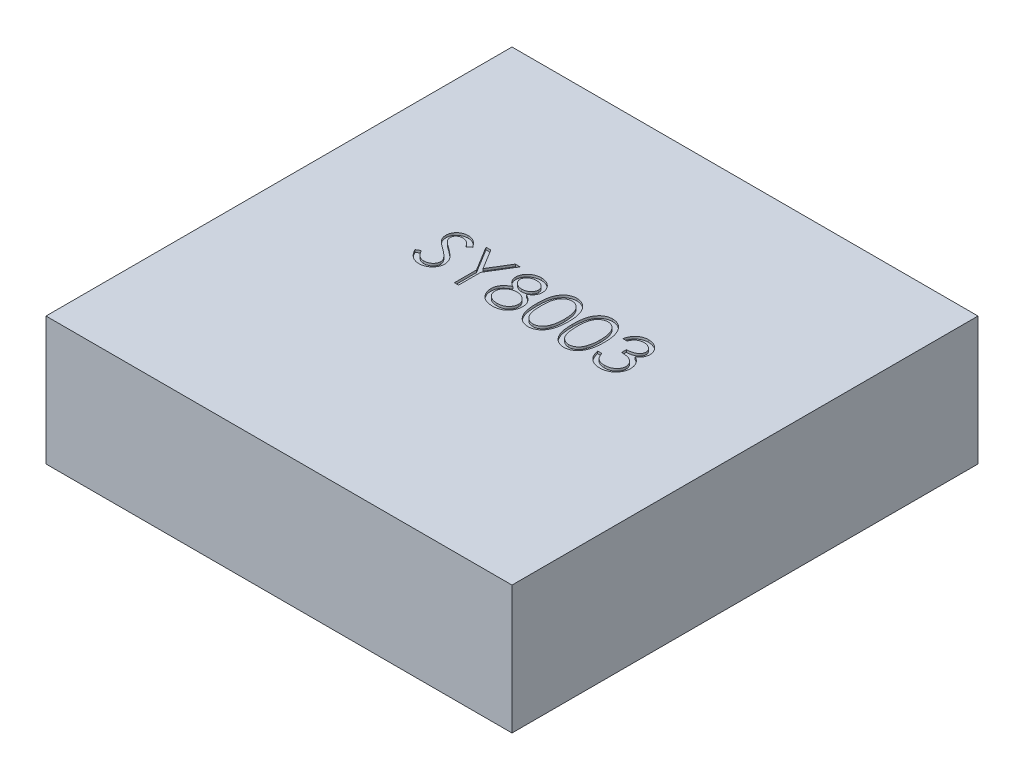
from build123d import *

# Parameters (mm, degrees)
BASES_W          = 2
BASES_H          = 2
BASE_DEPTH       = 0.55
PARTNUMBER_DEPTH = 0.01


with BuildPart() as part:
    # BaseS → Base (new body)
    with BuildSketch(Plane(origin=(0, 0, 0), x_dir=(1, 0, 0), z_dir=(0, 1, 0))):
        Rectangle(BASES_W, BASES_H)
    extrude(amount=BASE_DEPTH)

    # PartNumberS → PartNumber (cut)
    with BuildSketch(Plane(origin=(0, 0.55, 0), x_dir=(1, 0, 0), z_dir=(0, 1, 0))):
        with BuildLine():
            Line((0.33974359, 0.153846154), (0.321794872, 0.153846154))
            add(Edge.make_bspline(
                [(0.321794872, 0.153846154), (0.322281132, 0.155859439), (0.32323173, 0.159795246), (0.325214449, 0.165418518), (0.327374406, 0.170739862), (0.329968069, 0.175659638), (0.332797141, 0.180276718), (0.33603844, 0.184486382), (0.339542424, 0.188395694), (0.343418135, 0.191865022), (0.34748263, 0.195006607), (0.35179318, 0.197685181), (0.356263059, 0.199989419), (0.360923238, 0.201887718), (0.365787591, 0.203317748), (0.370812141, 0.204355279), (0.376010055, 0.205029057), (0.379538489, 0.205094815), (0.381330128, 0.205128205)],
                knots=[0, 0, 0, 0, 1.162005537, 2.271625781, 3.343758855, 4.383309926, 5.390229558, 6.379919256, 7.361854164, 8.333198761, 9.295911338, 10.242430842, 11.177959212, 12.116337295, 13.062827104, 14.020064771, 14.994644689, 16, 16, 16, 16], degree=3))
            add(Edge.make_bspline(
                [(0.381330128, 0.205128205), (0.383940571, 0.205049392), (0.389104514, 0.204893485), (0.396690974, 0.203469803), (0.404006792, 0.201216938), (0.410971892, 0.198104154), (0.417441517, 0.194264879), (0.42319787, 0.189695465), (0.428162928, 0.184484076), (0.432328321, 0.17872793), (0.43558975, 0.172576186), (0.437994685, 0.166244749), (0.439458781, 0.159748636), (0.439648527, 0.155362506), (0.43974359, 0.153165064)],
                knots=[0, 0, 0, 0, 1.083050992, 2.142477498, 3.193116406, 4.255571735, 5.30263384, 6.308962982, 7.297363603, 8.282367274, 9.249857812, 10.179914175, 11.08814088, 12, 12, 12, 12], degree=3))
            add(Edge.make_bspline(
                [(0.43974359, 0.153165064), (0.439677099, 0.15105039), (0.439546986, 0.146912301), (0.438442203, 0.140871073), (0.436582988, 0.135177267), (0.434007573, 0.129806915), (0.43067377, 0.124794067), (0.426635331, 0.120127445), (0.42186375, 0.11578635), (0.418247811, 0.113299523), (0.416386218, 0.112019231)],
                knots=[0, 0, 0, 0, 1.024540389, 2.004866551, 2.965041327, 3.920577974, 4.882998113, 5.874504559, 6.905732034, 8, 8, 8, 8], degree=3))
            add(Edge.make_bspline(
                [(0.416386218, 0.112019231), (0.418513747, 0.110991907), (0.422728997, 0.108956481), (0.428474741, 0.104964723), (0.43369062, 0.100355789), (0.436599404, 0.096759066), (0.438060897, 0.094951923)],
                knots=[0, 0, 0, 0, 1.015518401, 2.012035669, 3.001164323, 4, 4, 4, 4], degree=3))
            add(Edge.make_bspline(
                [(0.438060897, 0.094951923), (0.43902326, 0.093634337), (0.440932225, 0.091020742), (0.443288542, 0.086818661), (0.445426205, 0.082570004), (0.447091932, 0.078160895), (0.448381867, 0.073642437), (0.449303926, 0.069006872), (0.449876734, 0.064250413), (0.449958766, 0.061032557), (0.45, 0.059415064)],
                knots=[0, 0, 0, 0, 1.025084078, 2.033381695, 3.024893161, 4.013698104, 4.991890475, 5.976764909, 6.982997093, 8, 8, 8, 8], degree=3))
            add(Edge.make_bspline(
                [(0.45, 0.059415064), (0.449897456, 0.056614509), (0.449692852, 0.051026577), (0.447864047, 0.042770879), (0.445029005, 0.03470085), (0.441002894, 0.026982288), (0.43609618, 0.019760552), (0.430258618, 0.013299048), (0.423556538, 0.007744842), (0.416081929, 0.003104258), (0.407983808, -0.000605338), (0.399322345, -0.003180049), (0.390222342, -0.004856963), (0.383981925, -0.005036784), (0.380809295, -0.005128205)],
                knots=[0, 0, 0, 0, 0.955779014, 1.907060117, 2.875433937, 3.871313158, 4.872415639, 5.851225146, 6.836215519, 7.83643374, 8.849228613, 9.86973379, 10.916971861, 12, 12, 12, 12], degree=3))
            add(Edge.make_bspline(
                [(0.380809295, -0.005128205), (0.378671049, -0.005078593), (0.374463695, -0.004980973), (0.368278352, -0.004313624), (0.362374255, -0.003094767), (0.356743421, -0.001454578), (0.351380847, 0.00062495), (0.346302898, 0.00321459), (0.341478333, 0.006260962), (0.336952678, 0.009800024), (0.332726475, 0.013758958), (0.328912033, 0.018208044), (0.325445759, 0.023065038), (0.322420466, 0.028386356), (0.319698354, 0.034103228), (0.317459442, 0.040288856), (0.315488838, 0.046887943), (0.31457264, 0.051486671), (0.314102564, 0.053846154)],
                knots=[0, 0, 0, 0, 1.048658725, 2.063410685, 3.046034179, 4.001477787, 4.936774919, 5.862367409, 6.792675028, 7.730719943, 8.675894397, 9.627829632, 10.600096036, 11.597688215, 12.626045268, 13.701542398, 14.82072376, 16, 16, 16, 16], degree=3))
            Line((0.314102564, 0.053846154), (0.332051282, 0.053846154))
            add(Edge.make_bspline(
                [(0.332051282, 0.053846154), (0.332518899, 0.05230621), (0.333428454, 0.049310886), (0.334976699, 0.045000012), (0.336740601, 0.041048123), (0.338632861, 0.03742623), (0.340620201, 0.034098664), (0.342843911, 0.031153415), (0.345139291, 0.028461117), (0.346869539, 0.026944282), (0.347716346, 0.026201923)],
                knots=[0, 0, 0, 0, 1.198163088, 2.33053128, 3.407730985, 4.417276592, 5.372219308, 6.28897303, 7.162600585, 8, 8, 8, 8], degree=3))
            add(Edge.make_bspline(
                [(0.347716346, 0.026201923), (0.348836151, 0.02533859), (0.351072303, 0.023614588), (0.354716202, 0.021414495), (0.358548481, 0.019508151), (0.362652176, 0.018051939), (0.366938735, 0.01681893), (0.371477441, 0.016012043), (0.376228254, 0.015458434), (0.379472126, 0.01540958), (0.381129808, 0.015384615)],
                knots=[0, 0, 0, 0, 0.946170439, 1.889420265, 2.845303464, 3.807233317, 4.801018734, 5.828864929, 6.890507805, 8, 8, 8, 8], degree=3))
            add(Edge.make_bspline(
                [(0.381129808, 0.015384615), (0.383001436, 0.01541981), (0.386661245, 0.01548863), (0.392001522, 0.016121527), (0.397081948, 0.017043265), (0.401846115, 0.018466864), (0.40635643, 0.02022577), (0.410549667, 0.022434251), (0.414480873, 0.025025377), (0.418099696, 0.027970472), (0.421353725, 0.031194558), (0.42421884, 0.034566733), (0.426654535, 0.038072781), (0.428619311, 0.041732102), (0.430170771, 0.045529543), (0.431226954, 0.049475762), (0.431961326, 0.053538463), (0.432021133, 0.056300119), (0.432051282, 0.057692308)],
                knots=[0, 0, 0, 0, 1.217147791, 2.380027433, 3.494444702, 4.572153297, 5.609568379, 6.639424714, 7.649109417, 8.668170816, 9.669597737, 10.625200337, 11.543417969, 12.441394052, 13.322311151, 14.205496177, 15.095365482, 16, 16, 16, 16], degree=3))
            add(Edge.make_bspline(
                [(0.432051282, 0.057692308), (0.431963836, 0.059555813), (0.43178938, 0.06327355), (0.430457461, 0.068743126), (0.428266669, 0.074013035), (0.425199668, 0.078993366), (0.421466198, 0.083609132), (0.417102489, 0.087727502), (0.412072304, 0.091125793), (0.407442598, 0.093473717), (0.403341732, 0.095075835), (0.399832281, 0.096142976), (0.395903332, 0.097046613), (0.391602398, 0.097887315), (0.386897071, 0.09860282), (0.381792475, 0.099199495), (0.376287574, 0.099676926), (0.37247665, 0.099890132), (0.370512821, 0.1)],
                knots=[0, 0, 0, 0, 1.07054697, 2.135767047, 3.216561865, 4.33974944, 5.486079747, 6.621378074, 7.775625952, 8.963672916, 9.598146892, 10.304877434, 11.070270905, 11.915000392, 12.823868403, 13.805723172, 14.86925407, 16, 16, 16, 16], degree=3))
            Line((0.370512821, 0.1), (0.370512821, 0.120512821))
            add(Edge.make_bspline(
                [(0.370512821, 0.120512821), (0.372987173, 0.120554809), (0.377833821, 0.120637055), (0.384913496, 0.121631798), (0.391683399, 0.123007834), (0.397993499, 0.12511556), (0.403744854, 0.127563577), (0.408734545, 0.130412274), (0.412892668, 0.133578831), (0.416199015, 0.137112123), (0.4186864, 0.140901555), (0.420505074, 0.144851078), (0.421579378, 0.14899531), (0.421722788, 0.151823577), (0.421794872, 0.153245192)],
                knots=[0, 0, 0, 0, 1.321986639, 2.589447074, 3.816329219, 5.01088745, 6.139805852, 7.153945165, 8.075214402, 8.924034688, 9.728124013, 10.488707548, 11.240355623, 12, 12, 12, 12], degree=3))
            add(Edge.make_bspline(
                [(0.421794872, 0.153245192), (0.421771191, 0.154289635), (0.42172408, 0.156367504), (0.42112995, 0.159403222), (0.420237147, 0.162346133), (0.419009734, 0.165183722), (0.417366866, 0.16789631), (0.415400809, 0.170507021), (0.413059775, 0.173000951), (0.410377178, 0.175325541), (0.407496503, 0.177540926), (0.404339373, 0.179421705), (0.401000981, 0.181029994), (0.397477629, 0.182356252), (0.393757884, 0.183353925), (0.389859224, 0.184070259), (0.385774213, 0.184518125), (0.382987257, 0.184582606), (0.381570513, 0.184615385)],
                knots=[0, 0, 0, 0, 0.884392785, 1.759457502, 2.611959086, 3.489218968, 4.37281399, 5.2945488, 6.255912374, 7.266815255, 8.301784654, 9.332968512, 10.37626691, 11.440494194, 12.520033166, 13.637162961, 14.798855837, 16, 16, 16, 16], degree=3))
            add(Edge.make_bspline(
                [(0.381570513, 0.184615385), (0.379293275, 0.184535878), (0.374845299, 0.184380584), (0.368433018, 0.183020412), (0.362471913, 0.180850235), (0.357915418, 0.178259777), (0.354550699, 0.175702609), (0.352146303, 0.17346933), (0.349785131, 0.170987455), (0.347622521, 0.168104119), (0.345435436, 0.165014588), (0.343444319, 0.161561806), (0.341509479, 0.157835841), (0.340343619, 0.155201805), (0.33974359, 0.153846154)],
                knots=[0, 0, 0, 0, 1.472543308, 2.876219568, 4.221790263, 5.565193594, 6.249813518, 6.953379497, 7.687249741, 8.463570142, 9.283606569, 10.136032583, 11.040678096, 12, 12, 12, 12], degree=3))
        make_face()
        with BuildLine():
            add(Edge.make_bspline(
                [(0.16025641, 0.099919872), (0.160275154, 0.103125437), (0.160311564, 0.109352293), (0.160716617, 0.118425701), (0.161389494, 0.126937718), (0.162311629, 0.13488875), (0.1634338, 0.142280851), (0.164931827, 0.149094266), (0.166635416, 0.155360529), (0.168609842, 0.161100074), (0.170837715, 0.166390229), (0.17326253, 0.171328812), (0.175980518, 0.175908351), (0.178836342, 0.180201939), (0.181945603, 0.184139293), (0.18521982, 0.187776016), (0.188786784, 0.191028059), (0.192525242, 0.193990705), (0.19646904, 0.196587818), (0.200505764, 0.198875403), (0.204663198, 0.200829681), (0.208952694, 0.202366277), (0.213335698, 0.203635469), (0.21782753, 0.204503408), (0.222435608, 0.205049517), (0.225545976, 0.205101727), (0.227123397, 0.205128205)],
                knots=[0, 0, 0, 0, 1.646270934, 3.197905019, 4.663502075, 6.030701355, 7.308322542, 8.50163776, 9.611534131, 10.641858119, 11.616356847, 12.558055219, 13.465016945, 14.349605745, 15.204443733, 16.039544428, 16.859896111, 17.680448484, 18.487036065, 19.28249412, 20.06191084, 20.843045899, 21.620316918, 22.403196591, 23.190181807, 24, 24, 24, 24], degree=3))
            add(Edge.make_bspline(
                [(0.227123397, 0.205128205), (0.228713996, 0.20510033), (0.231877197, 0.205044895), (0.23655379, 0.204512098), (0.241122343, 0.203628034), (0.245563379, 0.202375407), (0.249913379, 0.200821368), (0.254138316, 0.198873533), (0.258264435, 0.196606169), (0.262226166, 0.193941948), (0.266067001, 0.190971532), (0.269692599, 0.187613665), (0.273103289, 0.183902253), (0.276341878, 0.179877003), (0.279316484, 0.175460713), (0.282149251, 0.170730192), (0.284684796, 0.165602714), (0.287126778, 0.16016383), (0.289234606, 0.15426305), (0.291135534, 0.147933635), (0.292671475, 0.141100824), (0.293950862, 0.133800467), (0.294941999, 0.126005754), (0.295663864, 0.117733393), (0.296045183, 0.108977942), (0.296116995, 0.102991779), (0.296153846, 0.099919872)],
                knots=[0, 0, 0, 0, 0.810914788, 1.612654377, 2.396697861, 3.181598691, 3.963628158, 4.749916497, 5.551656086, 6.361998678, 7.18212741, 8.025565596, 8.878627764, 9.750805457, 10.657531673, 11.591944965, 12.560506719, 13.57287815, 14.630710178, 15.753379473, 16.941251878, 18.199788006, 19.531962791, 20.947069417, 22.433333509, 24, 24, 24, 24], degree=3))
            add(Edge.make_bspline(
                [(0.296153846, 0.099919872), (0.296116613, 0.096861363), (0.296044065, 0.090901983), (0.295668139, 0.082185927), (0.294927646, 0.073957467), (0.294001361, 0.066196869), (0.292718448, 0.058936434), (0.29114101, 0.052151037), (0.289389563, 0.045811376), (0.287227575, 0.039969387), (0.284861249, 0.034543574), (0.282286666, 0.02947688), (0.27952839, 0.02472452), (0.276523319, 0.020324535), (0.273320267, 0.016245754), (0.269850679, 0.012560176), (0.26621236, 0.009178994), (0.262360222, 0.00617033), (0.258336705, 0.003536913), (0.254224757, 0.001181835), (0.249951421, -0.000717176), (0.245613538, -0.002347749), (0.24114906, -0.00359349), (0.236563552, -0.004454853), (0.231880339, -0.005058958), (0.228714535, -0.005105043), (0.227123397, -0.005128205)],
                knots=[0, 0, 0, 0, 1.561518951, 3.042555995, 4.452378317, 5.7783523, 7.031515105, 8.214008947, 9.334062868, 10.386615937, 11.391082383, 12.354592575, 13.286541444, 14.194233754, 15.072674879, 15.931287219, 16.775624067, 17.606195743, 18.42308326, 19.229000347, 20.022332153, 20.807536673, 21.593273796, 22.3848459, 23.188221202, 24, 24, 24, 24], degree=3))
            add(Edge.make_bspline(
                [(0.227123397, -0.005128205), (0.225546019, -0.005101556), (0.222435738, -0.00504901), (0.217827028, -0.004505368), (0.213353746, -0.003631339), (0.208993817, -0.002407533), (0.204724873, -0.000909543), (0.200605085, 0.001042096), (0.196588646, 0.003289757), (0.192686272, 0.005849496), (0.188971291, 0.008782163), (0.185422799, 0.012025837), (0.182129941, 0.015661461), (0.179065135, 0.019631628), (0.17615233, 0.023899813), (0.173472938, 0.028524291), (0.170994603, 0.033486726), (0.168729261, 0.038819178), (0.166720766, 0.04459946), (0.164946611, 0.050893699), (0.163545802, 0.057757449), (0.162346776, 0.065135585), (0.161379668, 0.073059809), (0.160719421, 0.081534425), (0.160311346, 0.090554151), (0.160275056, 0.096740995), (0.16025641, 0.099919872)],
                knots=[0, 0, 0, 0, 0.810891512, 1.598919785, 2.382837074, 3.152667961, 3.926044502, 4.706494248, 5.493654104, 6.291793342, 7.103789334, 7.925228297, 8.761435821, 9.622817696, 10.50288917, 11.416980706, 12.369136599, 13.353924996, 14.394355917, 15.514179734, 16.714354668, 17.994756427, 19.357759367, 20.818452758, 22.365282078, 24, 24, 24, 24], degree=3))
        make_face()
        with BuildLine():
            add(Edge.make_bspline(
                [(0.178205128, 0.1), (0.178211954, 0.097328646), (0.178225201, 0.092144072), (0.178571269, 0.084610171), (0.179042711, 0.077583295), (0.179650785, 0.071054522), (0.180553811, 0.06504595), (0.181565627, 0.059516253), (0.182796947, 0.054494697), (0.184253805, 0.049946822), (0.185913182, 0.045795447), (0.187724946, 0.04193252), (0.189671273, 0.03831241), (0.19184951, 0.034967632), (0.194221799, 0.03188728), (0.196734557, 0.029016832), (0.199481562, 0.026457005), (0.203281775, 0.023386899), (0.208298717, 0.020214377), (0.214619886, 0.017451743), (0.221115226, 0.015715603), (0.225523869, 0.015494817), (0.227724359, 0.015384615)],
                knots=[0, 0, 0, 0, 1.459021318, 2.831673884, 4.118529203, 5.306027144, 6.411944654, 7.436330062, 8.375795394, 9.233974572, 10.042671642, 10.816086306, 11.563610507, 12.285937304, 12.993564865, 13.685989202, 14.367179055, 15.041617293, 16.353048772, 17.594441528, 18.799311195, 20, 20, 20, 20], degree=3))
            add(Edge.make_bspline(
                [(0.227724359, 0.015384615), (0.229939083, 0.015475917), (0.234363959, 0.015658332), (0.240828747, 0.01741826), (0.247104762, 0.020073662), (0.252023159, 0.02321352), (0.255765019, 0.02620371), (0.258445989, 0.028753118), (0.260906678, 0.031607739), (0.263240511, 0.034687699), (0.265381029, 0.038051841), (0.267327494, 0.041683988), (0.269103686, 0.045594227), (0.270115631, 0.048323926), (0.270633013, 0.049719551)],
                knots=[0, 0, 0, 0, 1.353760809, 2.704726607, 4.075137775, 5.516104923, 6.260822281, 7.007110065, 7.778089737, 8.566572457, 9.372053459, 10.217411131, 11.088608312, 12, 12, 12, 12], degree=3))
            add(Edge.make_bspline(
                [(0.270633013, 0.049719551), (0.271235971, 0.051504108), (0.272460235, 0.055127523), (0.27403805, 0.060748303), (0.275280645, 0.066645604), (0.276398551, 0.072784182), (0.277161583, 0.079209308), (0.277775744, 0.085901101), (0.278137497, 0.092864607), (0.27818234, 0.09759575), (0.278205128, 0.1)],
                knots=[0, 0, 0, 0, 0.884706709, 1.796334032, 2.740027952, 3.714592787, 4.726048262, 5.777819803, 6.87074269, 8, 8, 8, 8], degree=3))
            add(Edge.make_bspline(
                [(0.278205128, 0.1), (0.278173689, 0.102403861), (0.278112187, 0.107106328), (0.277877102, 0.113993081), (0.27727004, 0.120534096), (0.276595805, 0.126757552), (0.275601678, 0.132628997), (0.274529803, 0.138197586), (0.273089734, 0.143394331), (0.271551461, 0.148300592), (0.269790867, 0.15286063), (0.267852825, 0.157095703), (0.26578301, 0.161026259), (0.263534882, 0.164641513), (0.261135129, 0.167957658), (0.258520412, 0.170908206), (0.255794448, 0.173584605), (0.251976323, 0.176639608), (0.246977792, 0.179754562), (0.240758041, 0.182621177), (0.234285433, 0.184267365), (0.229909807, 0.184499462), (0.227724359, 0.184615385)],
                knots=[0, 0, 0, 0, 1.31362396, 2.569729283, 3.763502607, 4.902122613, 5.988968491, 7.01645872, 7.998833611, 8.933434873, 9.825090667, 10.667526885, 11.477055099, 12.250526234, 12.991942729, 13.710640831, 14.402115721, 15.076753259, 16.378508321, 17.609869233, 18.806226677, 20, 20, 20, 20], degree=3))
            add(Edge.make_bspline(
                [(0.227724359, 0.184615385), (0.225512325, 0.184499302), (0.221084228, 0.184266925), (0.214544345, 0.182627311), (0.208275524, 0.179769427), (0.203290212, 0.176629291), (0.199469424, 0.173638531), (0.196778984, 0.171045019), (0.194256346, 0.16820809), (0.191932477, 0.165099409), (0.189755947, 0.161758531), (0.187757032, 0.158159173), (0.185956041, 0.154283095), (0.184294068, 0.150133585), (0.182832766, 0.145586102), (0.181627396, 0.140570731), (0.180513851, 0.135058623), (0.179725549, 0.129017508), (0.179024763, 0.122487099), (0.178574401, 0.115442681), (0.178224043, 0.107896145), (0.178211559, 0.102684765), (0.178205128, 0.1)],
                knots=[0, 0, 0, 0, 1.207732386, 2.417664972, 3.655092373, 4.956220595, 5.625982001, 6.301752483, 6.994047911, 7.697131622, 8.419323945, 9.170223765, 9.943494443, 10.752040957, 11.610060368, 12.549350801, 13.567764191, 14.679664412, 15.874934091, 17.154273443, 18.533957287, 20, 20, 20, 20], degree=3))
        make_face(mode=Mode.SUBTRACT)
        with BuildLine():
            add(Edge.make_bspline(
                [(0.006410256, 0.099919872), (0.006429, 0.103125437), (0.006465411, 0.109352293), (0.006870463, 0.118425701), (0.00754334, 0.126937718), (0.008465476, 0.13488875), (0.009587646, 0.142280851), (0.011085674, 0.149094266), (0.012789262, 0.155360529), (0.014763688, 0.161100074), (0.016991561, 0.166390229), (0.019416376, 0.171328812), (0.022134365, 0.175908351), (0.024990188, 0.180201939), (0.028099449, 0.184139293), (0.031373666, 0.187776016), (0.03494063, 0.191028059), (0.038679088, 0.193990705), (0.042622886, 0.196587818), (0.04665961, 0.198875403), (0.050817044, 0.200829681), (0.055106541, 0.202366277), (0.059489544, 0.203635469), (0.063981376, 0.204503408), (0.068589454, 0.205049517), (0.071699822, 0.205101727), (0.073277244, 0.205128205)],
                knots=[0, 0, 0, 0, 1.646270934, 3.197905019, 4.663502075, 6.030701355, 7.308322542, 8.50163776, 9.611534131, 10.641858119, 11.616356847, 12.558055219, 13.465016945, 14.349605745, 15.204443733, 16.039544428, 16.859896111, 17.680448484, 18.487036065, 19.28249412, 20.06191084, 20.843045899, 21.620316918, 22.403196591, 23.190181807, 24, 24, 24, 24], degree=3))
            add(Edge.make_bspline(
                [(0.073277244, 0.205128205), (0.074867842, 0.20510033), (0.078031043, 0.205044895), (0.082707636, 0.204512098), (0.087276189, 0.203628034), (0.091717225, 0.202375407), (0.096067225, 0.200821368), (0.100292162, 0.198873533), (0.104418281, 0.196606169), (0.108380012, 0.193941948), (0.112220847, 0.190971532), (0.115846445, 0.187613665), (0.119257136, 0.183902253), (0.122495724, 0.179877003), (0.12547033, 0.175460713), (0.128303098, 0.170730192), (0.130838643, 0.165602714), (0.133280624, 0.16016383), (0.135388452, 0.15426305), (0.13728938, 0.147933635), (0.138825321, 0.141100824), (0.140104708, 0.133800467), (0.141095845, 0.126005754), (0.14181771, 0.117733393), (0.142199029, 0.108977942), (0.142270841, 0.102991779), (0.142307692, 0.099919872)],
                knots=[0, 0, 0, 0, 0.810914788, 1.612654377, 2.396697861, 3.181598691, 3.963628158, 4.749916497, 5.551656086, 6.361998678, 7.18212741, 8.025565596, 8.878627764, 9.750805457, 10.657531673, 11.591944965, 12.560506719, 13.57287815, 14.630710178, 15.753379473, 16.941251878, 18.199788006, 19.531962791, 20.947069417, 22.433333509, 24, 24, 24, 24], degree=3))
            add(Edge.make_bspline(
                [(0.142307692, 0.099919872), (0.142270459, 0.096861363), (0.142197911, 0.090901983), (0.141821985, 0.082185927), (0.141081492, 0.073957467), (0.140155207, 0.066196869), (0.138872295, 0.058936434), (0.137294857, 0.052151037), (0.13554341, 0.045811376), (0.133381421, 0.039969387), (0.131015095, 0.034543574), (0.128440512, 0.02947688), (0.125682237, 0.02472452), (0.122677165, 0.020324535), (0.119474113, 0.016245754), (0.116004525, 0.012560176), (0.112366206, 0.009178994), (0.108514068, 0.00617033), (0.104490551, 0.003536913), (0.100378604, 0.001181835), (0.096105267, -0.000717176), (0.091767384, -0.002347749), (0.087302906, -0.00359349), (0.082717398, -0.004454853), (0.078034185, -0.005058958), (0.074868381, -0.005105043), (0.073277244, -0.005128205)],
                knots=[0, 0, 0, 0, 1.561518951, 3.042555995, 4.452378317, 5.7783523, 7.031515105, 8.214008947, 9.334062868, 10.386615937, 11.391082383, 12.354592575, 13.286541444, 14.194233754, 15.072674879, 15.931287219, 16.775624067, 17.606195743, 18.42308326, 19.229000347, 20.022332153, 20.807536673, 21.593273796, 22.3848459, 23.188221202, 24, 24, 24, 24], degree=3))
            add(Edge.make_bspline(
                [(0.073277244, -0.005128205), (0.071699866, -0.005101556), (0.068589584, -0.00504901), (0.063980874, -0.004505368), (0.059507592, -0.003631339), (0.055147663, -0.002407533), (0.050878719, -0.000909543), (0.046758931, 0.001042096), (0.042742492, 0.003289757), (0.038840118, 0.005849496), (0.035125137, 0.008782163), (0.031576645, 0.012025837), (0.028283787, 0.015661461), (0.025218982, 0.019631628), (0.022306177, 0.023899813), (0.019626784, 0.028524291), (0.017148449, 0.033486726), (0.014883107, 0.038819178), (0.012874612, 0.04459946), (0.011100457, 0.050893699), (0.009699648, 0.057757449), (0.008500622, 0.065135585), (0.007533515, 0.073059809), (0.006873267, 0.081534425), (0.006465192, 0.090554151), (0.006428903, 0.096740995), (0.006410256, 0.099919872)],
                knots=[0, 0, 0, 0, 0.810891512, 1.598919785, 2.382837074, 3.152667961, 3.926044502, 4.706494248, 5.493654104, 6.291793342, 7.103789334, 7.925228297, 8.761435821, 9.622817696, 10.50288917, 11.416980706, 12.369136599, 13.353924996, 14.394355917, 15.514179734, 16.714354668, 17.994756427, 19.357759367, 20.818452758, 22.365282078, 24, 24, 24, 24], degree=3))
        make_face()
        with BuildLine():
            add(Edge.make_bspline(
                [(0.024358974, 0.1), (0.0243658, 0.097328646), (0.024379047, 0.092144072), (0.024725116, 0.084610171), (0.025196557, 0.077583295), (0.025804632, 0.071054522), (0.026707657, 0.06504595), (0.027719474, 0.059516253), (0.028950793, 0.054494697), (0.030407651, 0.049946822), (0.032067028, 0.045795447), (0.033878792, 0.04193252), (0.035825119, 0.03831241), (0.038003356, 0.034967632), (0.040375645, 0.03188728), (0.042888403, 0.029016832), (0.045635408, 0.026457005), (0.049435622, 0.023386899), (0.054452563, 0.020214377), (0.060773732, 0.017451743), (0.067269072, 0.015715603), (0.071677715, 0.015494817), (0.073878205, 0.015384615)],
                knots=[0, 0, 0, 0, 1.459021318, 2.831673884, 4.118529203, 5.306027144, 6.411944654, 7.436330062, 8.375795394, 9.233974572, 10.042671642, 10.816086306, 11.563610507, 12.285937304, 12.993564865, 13.685989202, 14.367179055, 15.041617293, 16.353048772, 17.594441528, 18.799311195, 20, 20, 20, 20], degree=3))
            add(Edge.make_bspline(
                [(0.073878205, 0.015384615), (0.076092929, 0.015475917), (0.080517805, 0.015658332), (0.086982593, 0.01741826), (0.093258609, 0.020073662), (0.098177005, 0.02321352), (0.101918865, 0.02620371), (0.104599836, 0.028753118), (0.107060524, 0.031607739), (0.109394357, 0.034687699), (0.111534876, 0.038051841), (0.113481341, 0.041683988), (0.115257532, 0.045594227), (0.116269477, 0.048323926), (0.116786859, 0.049719551)],
                knots=[0, 0, 0, 0, 1.353760809, 2.704726607, 4.075137775, 5.516104923, 6.260822281, 7.007110065, 7.778089737, 8.566572457, 9.372053459, 10.217411131, 11.088608312, 12, 12, 12, 12], degree=3))
            add(Edge.make_bspline(
                [(0.116786859, 0.049719551), (0.117389817, 0.051504108), (0.118614081, 0.055127523), (0.120191896, 0.060748303), (0.121434491, 0.066645604), (0.122552397, 0.072784182), (0.123315429, 0.079209308), (0.12392959, 0.085901101), (0.124291343, 0.092864607), (0.124336186, 0.09759575), (0.124358974, 0.1)],
                knots=[0, 0, 0, 0, 0.884706709, 1.796334032, 2.740027952, 3.714592787, 4.726048262, 5.777819803, 6.87074269, 8, 8, 8, 8], degree=3))
            add(Edge.make_bspline(
                [(0.124358974, 0.1), (0.124327535, 0.102403861), (0.124266033, 0.107106328), (0.124030948, 0.113993081), (0.123423886, 0.120534096), (0.122749651, 0.126757552), (0.121755524, 0.132628997), (0.120683649, 0.138197586), (0.11924358, 0.143394331), (0.117705307, 0.148300592), (0.115944713, 0.15286063), (0.114006671, 0.157095703), (0.111936857, 0.161026259), (0.109688729, 0.164641513), (0.107288975, 0.167957658), (0.104674258, 0.170908206), (0.101948294, 0.173584605), (0.098130169, 0.176639608), (0.093131638, 0.179754562), (0.086911887, 0.182621177), (0.080439279, 0.184267365), (0.076063653, 0.184499462), (0.073878205, 0.184615385)],
                knots=[0, 0, 0, 0, 1.31362396, 2.569729283, 3.763502607, 4.902122613, 5.988968491, 7.01645872, 7.998833611, 8.933434873, 9.825090667, 10.667526885, 11.477055099, 12.250526234, 12.991942729, 13.710640831, 14.402115721, 15.076753259, 16.378508321, 17.609869233, 18.806226677, 20, 20, 20, 20], degree=3))
            add(Edge.make_bspline(
                [(0.073878205, 0.184615385), (0.071666171, 0.184499302), (0.067238074, 0.184266925), (0.060698191, 0.182627311), (0.054429371, 0.179769427), (0.049444058, 0.176629291), (0.04562327, 0.173638531), (0.04293283, 0.171045019), (0.040410192, 0.16820809), (0.038086323, 0.165099409), (0.035909793, 0.161758531), (0.033910878, 0.158159173), (0.032109888, 0.154283095), (0.030447914, 0.150133585), (0.028986612, 0.145586102), (0.027781243, 0.140570731), (0.026667697, 0.135058623), (0.025879396, 0.129017508), (0.02517861, 0.122487099), (0.024728247, 0.115442681), (0.024377889, 0.107896145), (0.024365406, 0.102684765), (0.024358974, 0.1)],
                knots=[0, 0, 0, 0, 1.207732386, 2.417664972, 3.655092373, 4.956220595, 5.625982001, 6.301752483, 6.994047911, 7.697131622, 8.419323945, 9.170223765, 9.943494443, 10.752040957, 11.610060368, 12.549350801, 13.567764191, 14.679664412, 15.874934091, 17.154273443, 18.533957287, 20, 20, 20, 20], degree=3))
        make_face(mode=Mode.SUBTRACT)
        with BuildLine():
            add(Edge.make_bspline(
                [(-0.050200321, 0.111418269), (-0.048563261, 0.110564672), (-0.045370447, 0.108899872), (-0.040823178, 0.106219253), (-0.036667464, 0.103394055), (-0.032788003, 0.10055772), (-0.029252955, 0.097601626), (-0.026101845, 0.094514017), (-0.023256838, 0.091371963), (-0.020775308, 0.088122258), (-0.018592632, 0.084773535), (-0.016706224, 0.081317005), (-0.015093812, 0.077760243), (-0.01381593, 0.074064424), (-0.012763256, 0.070283838), (-0.012038936, 0.066369667), (-0.011649398, 0.062347705), (-0.011575751, 0.059629516), (-0.011538462, 0.058253205)],
                knots=[0, 0, 0, 0, 1.272397273, 2.481599622, 3.635517121, 4.734568067, 5.792894095, 6.808321871, 7.773003508, 8.711915296, 9.623354172, 10.525449501, 11.423591555, 12.311487226, 13.218079475, 14.126165749, 15.051214107, 16, 16, 16, 16], degree=3))
            add(Edge.make_bspline(
                [(-0.011538462, 0.058253205), (-0.011582543, 0.05632762), (-0.011669796, 0.052516166), (-0.012429795, 0.046890674), (-0.013567679, 0.041427143), (-0.015229366, 0.036126772), (-0.017384417, 0.031018808), (-0.020040236, 0.026098878), (-0.023046591, 0.021286346), (-0.025461004, 0.018325238), (-0.026682692, 0.016826923)],
                knots=[0, 0, 0, 0, 1.025265484, 2.029385089, 3.018602448, 3.995076438, 4.983346944, 5.966715145, 6.97116228, 8, 8, 8, 8], degree=3))
            add(Edge.make_bspline(
                [(-0.026682692, 0.016826923), (-0.028273348, 0.015078707), (-0.031435003, 0.011603879), (-0.03685117, 0.007092404), (-0.042795278, 0.00330101), (-0.049244326, 0.000211188), (-0.056181074, -0.002193718), (-0.063604046, -0.003921862), (-0.071527712, -0.004911715), (-0.076973739, -0.0050548), (-0.079767628, -0.005128205)],
                knots=[0, 0, 0, 0, 0.954267603, 1.896743057, 2.838368354, 3.796610408, 4.779680527, 5.799409237, 6.871065594, 8, 8, 8, 8], degree=3))
            add(Edge.make_bspline(
                [(-0.079767628, -0.005128205), (-0.082454108, -0.005062349), (-0.087681723, -0.0049342), (-0.095290745, -0.004065947), (-0.102383492, -0.002544355), (-0.109001204, -0.000461806), (-0.115103987, 0.00224735), (-0.12067445, 0.005619259), (-0.125792962, 0.009518199), (-0.13030419, 0.014056146), (-0.134309243, 0.018916596), (-0.137827418, 0.023930974), (-0.140751651, 0.029099737), (-0.143227485, 0.034345815), (-0.145122801, 0.039742738), (-0.146435498, 0.045262739), (-0.147269173, 0.050896176), (-0.147380095, 0.054697984), (-0.147435897, 0.056610577)],
                knots=[0, 0, 0, 0, 1.256902934, 2.445805442, 3.576955095, 4.645999104, 5.686449165, 6.692658513, 7.68621702, 8.689161843, 9.678783111, 10.630372946, 11.551080876, 12.453998257, 13.34127905, 14.221779781, 15.105423033, 16, 16, 16, 16], degree=3))
            add(Edge.make_bspline(
                [(-0.147435897, 0.056610577), (-0.147402876, 0.058013959), (-0.147337613, 0.060787538), (-0.146885907, 0.064885214), (-0.14615971, 0.068873565), (-0.145173455, 0.072767322), (-0.143836825, 0.076538137), (-0.142222989, 0.080203878), (-0.140341163, 0.083768684), (-0.138165096, 0.087252049), (-0.135633552, 0.090605164), (-0.132767058, 0.093884935), (-0.129508322, 0.09704047), (-0.125893599, 0.100110323), (-0.121964197, 0.10314895), (-0.117618052, 0.105992135), (-0.11297038, 0.108841161), (-0.109667214, 0.110544494), (-0.107972756, 0.111418269)],
                knots=[0, 0, 0, 0, 0.941657376, 1.861047343, 2.762797495, 3.66048619, 4.553285746, 5.444104102, 6.34607688, 7.256116206, 8.197091036, 9.162375105, 10.176350973, 11.237807142, 12.343728897, 13.50695164, 14.721116704, 16, 16, 16, 16], degree=3))
            add(Edge.make_bspline(
                [(-0.107972756, 0.111418269), (-0.110292264, 0.112683113), (-0.114783479, 0.115132205), (-0.120730304, 0.119632023), (-0.125838339, 0.124505612), (-0.12996718, 0.129855886), (-0.133217022, 0.135515707), (-0.135446657, 0.141449665), (-0.136955027, 0.147547728), (-0.137104446, 0.151713797), (-0.137179487, 0.15380609)],
                knots=[0, 0, 0, 0, 1.166880483, 2.259407225, 3.286803203, 4.280235371, 5.237608625, 6.161067461, 7.076446754, 8, 8, 8, 8], degree=3))
            add(Edge.make_bspline(
                [(-0.137179487, 0.15380609), (-0.137086034, 0.155937379), (-0.136898178, 0.160221641), (-0.135379131, 0.166599134), (-0.132903699, 0.172862938), (-0.129536785, 0.178982693), (-0.125343229, 0.184751277), (-0.120311998, 0.189925045), (-0.114563238, 0.19445713), (-0.108125646, 0.198261482), (-0.101197861, 0.201357692), (-0.093888391, 0.203493601), (-0.086324591, 0.204889951), (-0.08117615, 0.205048045), (-0.078565705, 0.205128205)],
                knots=[0, 0, 0, 0, 0.888701115, 1.786444228, 2.72001202, 3.692817113, 4.693886446, 5.687152267, 6.695133018, 7.739871481, 8.800368666, 9.853104506, 10.91144658, 12, 12, 12, 12], degree=3))
            add(Edge.make_bspline(
                [(-0.078565705, 0.205128205), (-0.07602263, 0.205045557), (-0.071007976, 0.204882584), (-0.063636854, 0.203523334), (-0.056584004, 0.201253076), (-0.049873747, 0.198173234), (-0.043626211, 0.194379695), (-0.038106079, 0.189785359), (-0.033229932, 0.184634413), (-0.029196538, 0.178867579), (-0.025872944, 0.172771339), (-0.023558607, 0.16639291), (-0.022075637, 0.159870106), (-0.021888588, 0.155456506), (-0.021794872, 0.153245192)],
                knots=[0, 0, 0, 0, 1.072916533, 2.115669174, 3.151510826, 4.193348718, 5.225979165, 6.227137561, 7.216255879, 8.211077061, 9.189680878, 10.138522389, 11.067357538, 12, 12, 12, 12], degree=3))
            add(Edge.make_bspline(
                [(-0.021794872, 0.153245192), (-0.021876847, 0.151075097), (-0.022037841, 0.146813154), (-0.023392123, 0.14060021), (-0.025672884, 0.134781808), (-0.028786836, 0.129291925), (-0.032845435, 0.124230125), (-0.037794506, 0.119532041), (-0.04359459, 0.115159079), (-0.047952355, 0.112691287), (-0.050200321, 0.111418269)],
                knots=[0, 0, 0, 0, 0.975232327, 1.915300861, 2.843280834, 3.77672583, 4.742871857, 5.749627742, 6.839139064, 8, 8, 8, 8], degree=3))
        make_face()
        with BuildLine():
            add(Edge.make_bspline(
                [(-0.079567308, 0.184615385), (-0.080970211, 0.184578159), (-0.083714903, 0.184505331), (-0.087739398, 0.184124837), (-0.091566391, 0.183384653), (-0.095235865, 0.182399584), (-0.098697512, 0.181068842), (-0.101998343, 0.179503413), (-0.105082183, 0.177600209), (-0.107986257, 0.175465284), (-0.110600587, 0.173117117), (-0.112920847, 0.170670619), (-0.114848168, 0.16807774), (-0.116484803, 0.165402976), (-0.117672318, 0.162566943), (-0.118561707, 0.15965659), (-0.119162929, 0.15663514), (-0.11920798, 0.154570196), (-0.119230769, 0.153525641)],
                knots=[0, 0, 0, 0, 1.203892937, 2.355340988, 3.463153438, 4.544400666, 5.610487187, 6.640501085, 7.674077295, 8.714426146, 9.728707835, 10.68524104, 11.601827946, 12.495867327, 13.368432065, 14.231010473, 15.105153427, 16, 16, 16, 16], degree=3))
            add(Edge.make_bspline(
                [(-0.119230769, 0.153525641), (-0.119191491, 0.15248104), (-0.119113872, 0.15041676), (-0.118513579, 0.147368425), (-0.117618901, 0.144372902), (-0.116210292, 0.141501422), (-0.114520786, 0.138654373), (-0.112435559, 0.135902911), (-0.109950472, 0.13323746), (-0.107148904, 0.130680692), (-0.104096816, 0.128286477), (-0.100863442, 0.126208009), (-0.097489362, 0.124468917), (-0.094009244, 0.123021523), (-0.090387618, 0.121896384), (-0.086646677, 0.121098175), (-0.082785791, 0.120602061), (-0.080169758, 0.120542803), (-0.078846154, 0.120512821)],
                knots=[0, 0, 0, 0, 0.873023192, 1.725219244, 2.590779336, 3.480155217, 4.391973325, 5.357036234, 6.360879153, 7.436073238, 8.526419356, 9.601555421, 10.645666583, 11.697338044, 12.750135903, 13.812665442, 14.89329948, 16, 16, 16, 16], degree=3))
            add(Edge.make_bspline(
                [(-0.078846154, 0.120512821), (-0.077146148, 0.120562699), (-0.073762927, 0.120661962), (-0.068775537, 0.121584886), (-0.063926243, 0.123036653), (-0.059266877, 0.125022937), (-0.054918043, 0.127515958), (-0.051041468, 0.130500701), (-0.047670217, 0.13390825), (-0.044839325, 0.137685555), (-0.042644476, 0.141705645), (-0.040935802, 0.145739948), (-0.039938018, 0.149831504), (-0.039807871, 0.152572473), (-0.03974359, 0.153926282)],
                knots=[0, 0, 0, 0, 1.076279235, 2.141928126, 3.20205304, 4.278698113, 5.344010996, 6.36967002, 7.368914609, 8.37248503, 9.349703398, 10.264243087, 11.142681841, 12, 12, 12, 12], degree=3))
            add(Edge.make_bspline(
                [(-0.03974359, 0.153926282), (-0.039773984, 0.154876456), (-0.039834312, 0.156762414), (-0.040331458, 0.159547463), (-0.041152934, 0.162269154), (-0.04226511, 0.164949969), (-0.043728527, 0.167552297), (-0.045463623, 0.170117045), (-0.047571309, 0.172586517), (-0.04993682, 0.175018262), (-0.052619414, 0.177268778), (-0.055613924, 0.179247904), (-0.058904995, 0.18092861), (-0.062492707, 0.182293682), (-0.066363845, 0.183318959), (-0.070500581, 0.184086751), (-0.074937406, 0.1845195), (-0.077990535, 0.18458273), (-0.079567308, 0.184615385)],
                knots=[0, 0, 0, 0, 0.814439003, 1.616544685, 2.417341072, 3.248991801, 4.09997495, 4.973547432, 5.9003056, 6.880240646, 7.880314356, 8.896779544, 9.951930927, 11.043077905, 12.18215768, 13.381699519, 14.647792085, 16, 16, 16, 16], degree=3))
        make_face(mode=Mode.SUBTRACT)
        with BuildLine():
            add(Edge.make_bspline(
                [(-0.078405449, 0.1), (-0.080184065, 0.099968363), (-0.083673276, 0.0999063), (-0.088785101, 0.099215471), (-0.093690996, 0.098253792), (-0.098374421, 0.096794887), (-0.102833398, 0.094897944), (-0.107092065, 0.092615971), (-0.111117844, 0.089918517), (-0.114855143, 0.086839853), (-0.118267905, 0.08352217), (-0.121262093, 0.080010048), (-0.123804809, 0.07636876), (-0.125852423, 0.072552062), (-0.127533093, 0.06864077), (-0.128636743, 0.064537478), (-0.12934427, 0.060321072), (-0.129439277, 0.057454781), (-0.129487179, 0.056009615)],
                knots=[0, 0, 0, 0, 1.140299081, 2.23698856, 3.303958914, 4.344563908, 5.37730929, 6.408454204, 7.439741482, 8.480804886, 9.510774543, 10.48932336, 11.43758569, 12.353841022, 13.263987381, 14.161954604, 15.073269652, 16, 16, 16, 16], degree=3))
            add(Edge.make_bspline(
                [(-0.129487179, 0.056009615), (-0.129409279, 0.054213564), (-0.129254726, 0.050650239), (-0.128028633, 0.045383778), (-0.126060888, 0.040285432), (-0.12331659, 0.035396749), (-0.119918443, 0.030828171), (-0.115739787, 0.026845955), (-0.111040311, 0.023307585), (-0.105661005, 0.02044584), (-0.099785093, 0.01816042), (-0.093414137, 0.016585794), (-0.08663957, 0.015543425), (-0.081961879, 0.015438386), (-0.079567308, 0.015384615)],
                knots=[0, 0, 0, 0, 0.898778495, 1.783155532, 2.693654817, 3.627872908, 4.583023416, 5.533784346, 6.509005473, 7.520592997, 8.575161974, 9.658835044, 10.801527049, 12, 12, 12, 12], degree=3))
            add(Edge.make_bspline(
                [(-0.079567308, 0.015384615), (-0.077695858, 0.015420547), (-0.074049674, 0.015490554), (-0.068730477, 0.016108514), (-0.063710789, 0.017088492), (-0.059000343, 0.018513838), (-0.054546409, 0.020253837), (-0.050424503, 0.022492241), (-0.046528587, 0.025038088), (-0.043050638, 0.028058554), (-0.039883026, 0.031285954), (-0.037121123, 0.034702528), (-0.034723549, 0.038215421), (-0.03284178, 0.04190402), (-0.031337423, 0.045697558), (-0.030256077, 0.049631016), (-0.029588864, 0.053716458), (-0.029521385, 0.056487833), (-0.029487179, 0.057892628)],
                knots=[0, 0, 0, 0, 1.224942928, 2.386581632, 3.501229538, 4.569074225, 5.605009692, 6.626002462, 7.634866581, 8.645888296, 9.63523824, 10.59253846, 11.518950513, 12.414518923, 13.29783783, 14.186679152, 15.080837789, 16, 16, 16, 16], degree=3))
            add(Edge.make_bspline(
                [(-0.029487179, 0.057892628), (-0.029538942, 0.059257048), (-0.029641009, 0.061947445), (-0.03028882, 0.065934103), (-0.03142687, 0.069785693), (-0.032988436, 0.07354855), (-0.035067348, 0.077146433), (-0.037515626, 0.080673071), (-0.040469576, 0.084030582), (-0.043807439, 0.087245045), (-0.047445094, 0.090217373), (-0.051311788, 0.092846769), (-0.055377757, 0.095061176), (-0.059634397, 0.096862119), (-0.064072258, 0.098278545), (-0.068688074, 0.099268031), (-0.073487249, 0.099890865), (-0.076747528, 0.099963211), (-0.078405449, 0.1)],
                knots=[0, 0, 0, 0, 0.917430815, 1.809013306, 2.70690318, 3.612392954, 4.541220862, 5.495268465, 6.494511384, 7.542276156, 8.608045339, 9.649016899, 10.681629292, 11.715607085, 12.752076957, 13.808767841, 14.885711793, 16, 16, 16, 16], degree=3))
        make_face(mode=Mode.SUBTRACT)
        Polygon((-0.311538462, 0.2), (-0.290985577, 0.2), (-0.238421474, 0.1140625), (-0.1859375, 0.2), (-0.165384615, 0.2), (-0.229487179, 0.095072115), (-0.229487179, 0), (-0.247435897, 0), (-0.247435897, 0.095072115), align=None)
        with BuildLine():
            Line((-0.455128205, 0.038581731), (-0.438221154, 0.048717949))
            add(Edge.make_bspline(
                [(-0.438221154, 0.048717949), (-0.436648683, 0.046085698), (-0.43363589, 0.041042408), (-0.428610098, 0.034227662), (-0.423402503, 0.028435539), (-0.417974541, 0.023699733), (-0.412359344, 0.019971225), (-0.406520255, 0.017331098), (-0.400476952, 0.015684471), (-0.396364162, 0.015484466), (-0.394310897, 0.015384615)],
                knots=[0, 0, 0, 0, 1.272034388, 2.437168799, 3.508375237, 4.49857839, 5.41946034, 6.295179144, 7.148887113, 8, 8, 8, 8], degree=3))
            add(Edge.make_bspline(
                [(-0.394310897, 0.015384615), (-0.392557363, 0.015433454), (-0.389080976, 0.015530276), (-0.383963133, 0.016460608), (-0.378992744, 0.017889872), (-0.374272251, 0.019936783), (-0.369866787, 0.022413267), (-0.366003547, 0.025404478), (-0.362663769, 0.028753404), (-0.35993182, 0.032489555), (-0.357835818, 0.036507678), (-0.356224843, 0.040632018), (-0.355330838, 0.044927365), (-0.355196167, 0.047819391), (-0.355128205, 0.049278846)],
                knots=[0, 0, 0, 0, 1.095163259, 2.171163733, 3.241058638, 4.321873601, 5.38011039, 6.391990106, 7.366004449, 8.327778327, 9.272591725, 10.192022065, 11.087607919, 12, 12, 12, 12], degree=3))
            add(Edge.make_bspline(
                [(-0.355128205, 0.049278846), (-0.355212451, 0.050944038), (-0.355383712, 0.054329128), (-0.356831225, 0.059323394), (-0.359108325, 0.064265827), (-0.361209047, 0.067323042), (-0.362299679, 0.068910256)],
                knots=[0, 0, 0, 0, 0.938893495, 1.908633276, 2.914225137, 4, 4, 4, 4], degree=3))
            add(Edge.make_bspline(
                [(-0.362299679, 0.068910256), (-0.363195143, 0.070055789), (-0.365075057, 0.072460692), (-0.368306915, 0.07604042), (-0.372099264, 0.079732901), (-0.376322325, 0.083679133), (-0.38112993, 0.087695578), (-0.386371502, 0.091973765), (-0.392180865, 0.096350998), (-0.396255122, 0.099286574), (-0.398357372, 0.100801282)],
                knots=[0, 0, 0, 0, 0.722233717, 1.516239348, 2.393582979, 3.351407094, 4.387010283, 5.505090956, 6.712668013, 8, 8, 8, 8], degree=3))
            add(Edge.make_bspline(
                [(-0.398357372, 0.100801282), (-0.4004616, 0.102300058), (-0.404484725, 0.105165605), (-0.410110929, 0.109418421), (-0.415142041, 0.113306642), (-0.419555699, 0.116866872), (-0.423349962, 0.120099592), (-0.426554729, 0.12297376), (-0.42908836, 0.125567106), (-0.430497251, 0.127249468), (-0.431129808, 0.128004808)],
                knots=[0, 0, 0, 0, 1.452282411, 2.77665338, 3.964542531, 5.026858415, 5.96415736, 6.766646006, 7.446254459, 8, 8, 8, 8], degree=3))
            add(Edge.make_bspline(
                [(-0.431129808, 0.128004808), (-0.432013953, 0.12918201), (-0.433752744, 0.131497136), (-0.436047944, 0.135115699), (-0.437998753, 0.138819886), (-0.43952803, 0.142619649), (-0.440815813, 0.146461645), (-0.441681981, 0.150396002), (-0.442224346, 0.154405066), (-0.442279889, 0.15710298), (-0.442307692, 0.158453526)],
                knots=[0, 0, 0, 0, 1.068054152, 2.10047183, 3.106115577, 4.101338837, 5.06977816, 6.043150881, 7.020423561, 8, 8, 8, 8], degree=3))
            add(Edge.make_bspline(
                [(-0.442307692, 0.158453526), (-0.442233109, 0.160569513), (-0.442085536, 0.164756259), (-0.440837507, 0.170872307), (-0.438867627, 0.176711531), (-0.436107919, 0.182216121), (-0.432550356, 0.187242749), (-0.428433443, 0.191849234), (-0.42352993, 0.195721724), (-0.41814978, 0.19910527), (-0.412260844, 0.201753609), (-0.406089936, 0.203751379), (-0.399627246, 0.204883337), (-0.395249924, 0.20504578), (-0.393028846, 0.205128205)],
                knots=[0, 0, 0, 0, 1.005424448, 1.989358655, 2.955360095, 3.929531133, 4.905563448, 5.876582895, 6.856512386, 7.866279853, 8.892233794, 9.918561126, 10.94386622, 12, 12, 12, 12], degree=3))
            add(Edge.make_bspline(
                [(-0.393028846, 0.205128205), (-0.39067204, 0.205046916), (-0.385985106, 0.204885259), (-0.379090865, 0.203479686), (-0.37245311, 0.201153933), (-0.367113495, 0.198514581), (-0.36293448, 0.195878501), (-0.359747467, 0.193477368), (-0.356517898, 0.190713076), (-0.353219723, 0.187578262), (-0.349908829, 0.184044162), (-0.34653606, 0.18013498), (-0.34309353, 0.175874605), (-0.34087891, 0.172833205), (-0.33974359, 0.171274038)],
                knots=[0, 0, 0, 0, 1.286793592, 2.559021753, 3.825965368, 5.121522368, 5.803751409, 6.523245864, 7.299691795, 8.125521123, 9.008227632, 9.944561021, 10.946284179, 12, 12, 12, 12], degree=3))
            Line((-0.33974359, 0.171274038), (-0.355969551, 0.158974359))
            add(Edge.make_bspline(
                [(-0.355969551, 0.158974359), (-0.356949319, 0.16023657), (-0.358836122, 0.162667293), (-0.361700664, 0.166071368), (-0.364400587, 0.169180881), (-0.36706061, 0.171881746), (-0.369540246, 0.174321868), (-0.371946934, 0.176410997), (-0.37424604, 0.178169602), (-0.377144149, 0.180046377), (-0.380785161, 0.181906748), (-0.385355706, 0.183480981), (-0.390132065, 0.184426985), (-0.393385187, 0.184552064), (-0.395032051, 0.184615385)],
                knots=[0, 0, 0, 0, 1.181633172, 2.275549214, 3.290209073, 4.226197932, 5.078386478, 5.862611352, 6.581680152, 7.217281963, 8.414376989, 9.595101626, 10.782541182, 12, 12, 12, 12], degree=3))
            add(Edge.make_bspline(
                [(-0.395032051, 0.184615385), (-0.397098138, 0.184546145), (-0.401082392, 0.184412622), (-0.406738977, 0.182954337), (-0.411830059, 0.180658231), (-0.416204491, 0.177440232), (-0.419846604, 0.173627604), (-0.422481202, 0.169240241), (-0.424066925, 0.164395532), (-0.424260427, 0.161016009), (-0.424358974, 0.159294872)],
                knots=[0, 0, 0, 0, 1.14458467, 2.207223713, 3.21896685, 4.227309161, 5.202851033, 6.127160689, 7.046193047, 8, 8, 8, 8], degree=3))
            add(Edge.make_bspline(
                [(-0.424358974, 0.159294872), (-0.42433651, 0.158223359), (-0.424291544, 0.15607858), (-0.423664413, 0.152909928), (-0.422858737, 0.14974928), (-0.421582015, 0.146610847), (-0.419819427, 0.14343974), (-0.417504845, 0.140181355), (-0.414589799, 0.136806972), (-0.412356827, 0.134612265), (-0.411177885, 0.133453526)],
                knots=[0, 0, 0, 0, 0.858281714, 1.717966888, 2.583508476, 3.4729293, 4.427298488, 5.488583878, 6.674047936, 8, 8, 8, 8], degree=3))
            add(Edge.make_bspline(
                [(-0.411177885, 0.133453526), (-0.410740092, 0.133062838), (-0.409699997, 0.132134655), (-0.407798515, 0.130615096), (-0.405287498, 0.128740652), (-0.402232515, 0.126421377), (-0.398577237, 0.123731008), (-0.394321263, 0.120703944), (-0.389512032, 0.117241918), (-0.386099351, 0.114821487), (-0.384294872, 0.113541667)],
                knots=[0, 0, 0, 0, 0.420754252, 0.999615792, 1.744751191, 2.668019286, 3.750313428, 4.999500688, 6.413464383, 8, 8, 8, 8], degree=3))
            add(Edge.make_bspline(
                [(-0.384294872, 0.113541667), (-0.382124248, 0.11196216), (-0.377921136, 0.108903665), (-0.371940703, 0.104308484), (-0.3665182, 0.099814326), (-0.361634588, 0.095449891), (-0.357241622, 0.091248286), (-0.353388038, 0.087158961), (-0.350034571, 0.083211214), (-0.34642433, 0.078149924), (-0.342735311, 0.071933862), (-0.339567225, 0.064317963), (-0.337569605, 0.056672459), (-0.337308376, 0.051533782), (-0.337179487, 0.048998397)],
                knots=[0, 0, 0, 0, 1.163667725, 2.253281268, 3.268753668, 4.215851969, 5.092017293, 5.902905408, 6.650798638, 7.335211899, 8.59617414, 9.77448103, 10.901945474, 12, 12, 12, 12], degree=3))
            add(Edge.make_bspline(
                [(-0.337179487, 0.048998397), (-0.337217038, 0.047205348), (-0.33729141, 0.043654069), (-0.33814632, 0.038439493), (-0.339398872, 0.033374872), (-0.341286714, 0.028522808), (-0.343590894, 0.023794536), (-0.34651468, 0.019314085), (-0.34990369, 0.014982291), (-0.353791334, 0.010914663), (-0.358045386, 0.007180594), (-0.362541597, 0.003858934), (-0.367287327, 0.001089315), (-0.372256831, -0.001170733), (-0.37745125, -0.002938363), (-0.382868837, -0.004219098), (-0.388518524, -0.005005139), (-0.392358551, -0.005086725), (-0.394310897, -0.005128205)],
                knots=[0, 0, 0, 0, 0.983748083, 1.948392443, 2.894712957, 3.844097841, 4.80183111, 5.778335162, 6.776009319, 7.81870978, 8.863265674, 9.881300176, 10.883814829, 11.87499822, 12.874611388, 13.892143829, 14.928324115, 16, 16, 16, 16], degree=3))
            add(Edge.make_bspline(
                [(-0.394310897, -0.005128205), (-0.395821488, -0.005098995), (-0.398823646, -0.005040942), (-0.403264188, -0.004527726), (-0.407615022, -0.003801606), (-0.411821552, -0.002648802), (-0.415937976, -0.001250117), (-0.419946389, 0.000472073), (-0.423848735, 0.002535913), (-0.427666883, 0.004895629), (-0.431391121, 0.007641786), (-0.434986519, 0.010840271), (-0.438571044, 0.014402872), (-0.442038895, 0.018426332), (-0.445460218, 0.022845651), (-0.448767556, 0.027702176), (-0.452029368, 0.032969454), (-0.454075966, 0.03667603), (-0.455128205, 0.038581731)],
                knots=[0, 0, 0, 0, 0.915332311, 1.819136955, 2.706846663, 3.586547465, 4.459518054, 5.340707479, 6.227863349, 7.133153174, 8.059268498, 9.028702269, 10.047606654, 11.120612155, 12.245963614, 13.433783089, 14.680604001, 16, 16, 16, 16], degree=3))
        make_face()
    extrude(amount=-PARTNUMBER_DEPTH, mode=Mode.SUBTRACT)


solid = part.part
